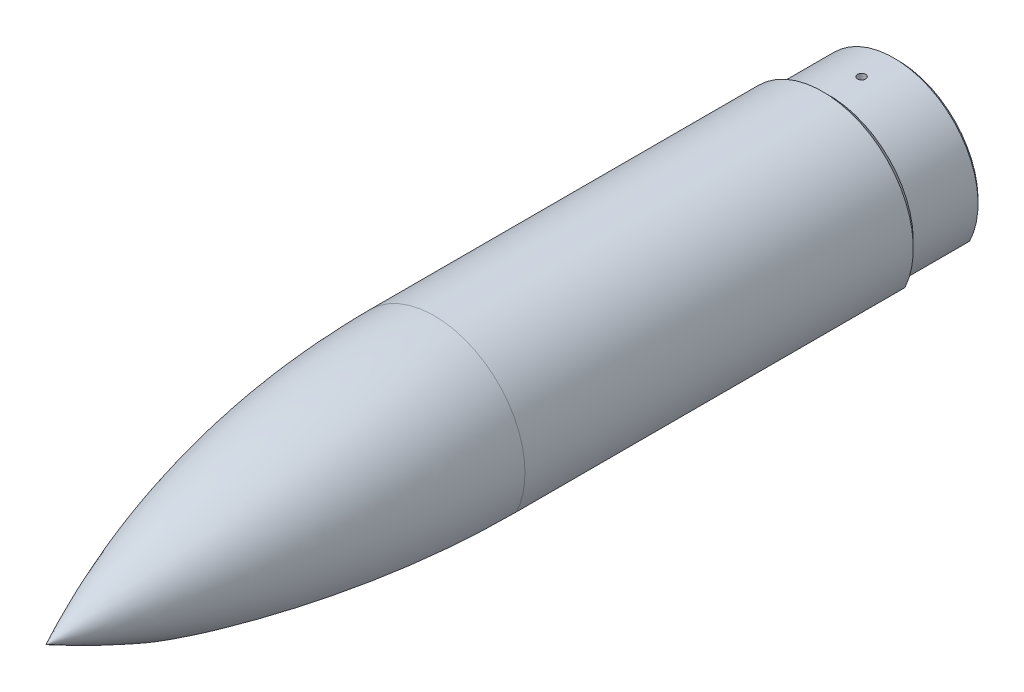
from build123d import *

# Parameters (mm, degrees)
CUT_EXTRUDE1_START = -153.834825
SKETCH2_R          = 80.518
CUT_EXTRUDE1_DEPTH = 153.834825
CUT_EXTRUDE2_REACH = 19.78
SKETCH3_R          = 0.8001


with BuildPart() as part:
    # Sketch1 → Revolve1 (revolve)
    with BuildSketch(Plane(origin=(0, 0, 0), x_dir=(0, 0, -1), z_dir=(1, 0, 0))):
        with BuildLine():
            Line((152.4, 17.78), (76.2, 17.78))
            ThreePointArc((76.2, 17.78), (37.076578626, 13.276091602), (0, 0))
            Line((0, 0), (5.927395299, 0))
            ThreePointArc((5.927395299, 0), (40.246917478, 11.386225076), (76.2, 15.24))
            Line((76.2, 15.24), (153.67, 15.24))
            Line((153.67, 15.24), (167.04, 15.24))
            Line((167.04, 15.24), (167.04, 15.84))
            Line((167.04, 15.84), (166.37, 16.51))
            Line((166.37, 16.51), (153.67, 16.51))
            Line((153.67, 16.51), (152.4, 17.78))
        make_face()
    revolve(axis=Axis((0, 0, 0), (0, 0, -1)))

    # Sketch2 → Cut-Extrude1 (cut)
    with BuildSketch(Plane(origin=(0, 0, -167.04), x_dir=(-1, 0, 0), z_dir=(0, 0, -1)).offset(CUT_EXTRUDE1_START)):
        with Locations((0, -86.36)):
            Circle(SKETCH2_R)
    extrude(amount=CUT_EXTRUDE1_DEPTH, mode=Mode.SUBTRACT)

    # Sketch3 → Cut-Extrude2 (cut, up to next)
    with BuildSketch(Plane(origin=(0, 0, 0), x_dir=(1, 0, 0), z_dir=(0, 1, 0)), mode=Mode.PRIVATE) as cut_extrude2_sk1:
        with Locations((0, 160.02)):
            Circle(SKETCH3_R)
    cut_extrude2_tool1 = extrude(cut_extrude2_sk1.sketch, amount=CUT_EXTRUDE2_REACH, mode=Mode.PRIVATE) & part.part
    add(cut_extrude2_tool1.solids().sort_by_distance((0, 0, -160.02))[0], mode=Mode.SUBTRACT)


solid = part.part
